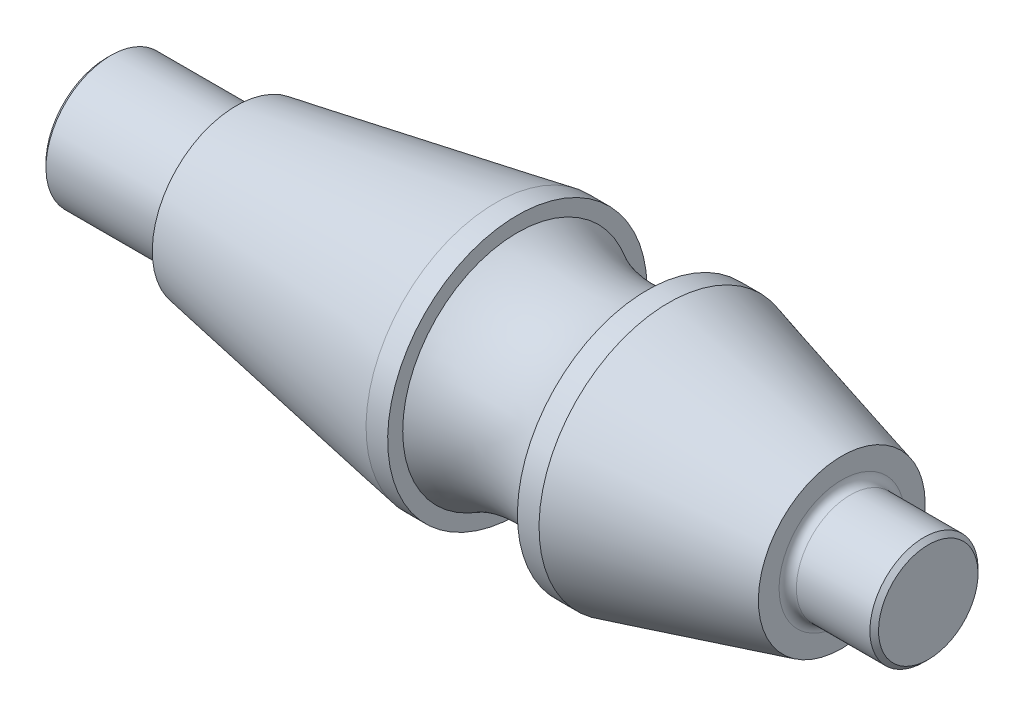
from build123d import *

# Parameters (mm, degrees)
CHANFRO1_SIZE                    = 1
FILETE1_R                        = 2
FURO_ROSCADO_DE_M101_D           = 8.5
FURO_ROSCADO_DE_M101_DEPTH       = 15
FURO_ROSCADO_DE_M101_CSINK_D     = 10.05
FURO_ROSCADO_DE_M101_CSINK_ANGLE = 90
FURO_ROSCADO_DE_M101_TIP         = 2.553657631


with BuildPart() as part:
    # Esboço1 → Revolução1 (revolve)
    with BuildSketch(Plane.XY):
        with BuildLine():
            Line((-95, 0), (-95, 15))
            Line((-95, 15), (-65, 15))
            Line((-65, 15), (-65, 19.420381157))
            Line((-65, 19.420381157), (-5, 30))
            Line((-5, 30), (0, 30))
            Line((0, 30), (0, 26.519237886))
            ThreePointArc((0, 26.519237886), (15, 22.5), (30, 26.519237886))
            Line((30, 26.519237886), (30, 30))
            Line((30, 30), (35, 30))
            Line((35, 30), (75, 19.282032303))
            Line((75, 19.282032303), (75, 12.5))
            Line((75, 12.5), (95, 12.5))
            Line((95, 12.5), (95, 0))
            Line((95, 0), (-95, 0))
        make_face()
    revolve(axis=Axis((-95, 0, 0), (1, 0, 0)))

    # Chanfro1
    chanfro1_edges = [part.edges().sort_by_distance(p)[0] for p in [
        (-95, -15, 0),
        (95, -12.5, 0),
    ]]
    chamfer(chanfro1_edges, length=CHANFRO1_SIZE)

    # Filete1
    filete1_edges = [part.edges().sort_by_distance(p)[0] for p in [
        (-65, -15, 0),
        (75, -12.5, 0),
    ]]
    fillet(filete1_edges, radius=FILETE1_R)

    # Furo roscado de M101
    with Locations(Plane.ZY.offset(95)):
        with Locations((0, 0)):
            CounterSinkHole(FURO_ROSCADO_DE_M101_D / 2, FURO_ROSCADO_DE_M101_CSINK_D / 2, depth=FURO_ROSCADO_DE_M101_DEPTH, counter_sink_angle=FURO_ROSCADO_DE_M101_CSINK_ANGLE)
            with Locations((0, 0, -(FURO_ROSCADO_DE_M101_DEPTH + FURO_ROSCADO_DE_M101_TIP / 2))):  # 118° drill point
                Cone(0, FURO_ROSCADO_DE_M101_D / 2, FURO_ROSCADO_DE_M101_TIP, mode=Mode.SUBTRACT)


solid = part.part
